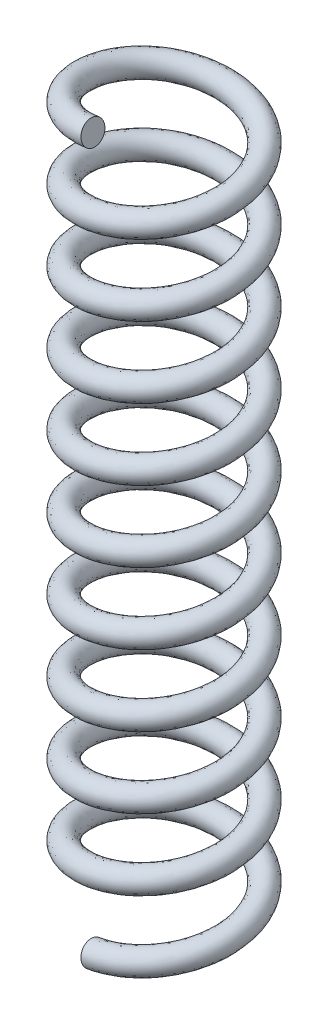
from build123d import *

# Parameters (mm, degrees)
SWEEP2_PITCH  = 15
SWEEP2_HEIGHT = 150
SWEEP2_RADIUS = 15
SKETCH4_R     = 2.5


with BuildPart() as part:
    # Sweep2: sweep along a helix
    with BuildLine() as sweep2_path:
        Helix(SWEEP2_PITCH, SWEEP2_HEIGHT, SWEEP2_RADIUS, center=(0, 0, 0), direction=(0, 1, 0))
    # Sketch4 → Sweep2 (sweep)
    with BuildSketch(Plane(origin=(0, 0, 15), x_dir=(0, 0, -1), z_dir=(0.987570492, 0.157176725, 0))):
        Circle(SKETCH4_R)
    sweep(path=sweep2_path.line, is_frenet=True)


solid = part.part
